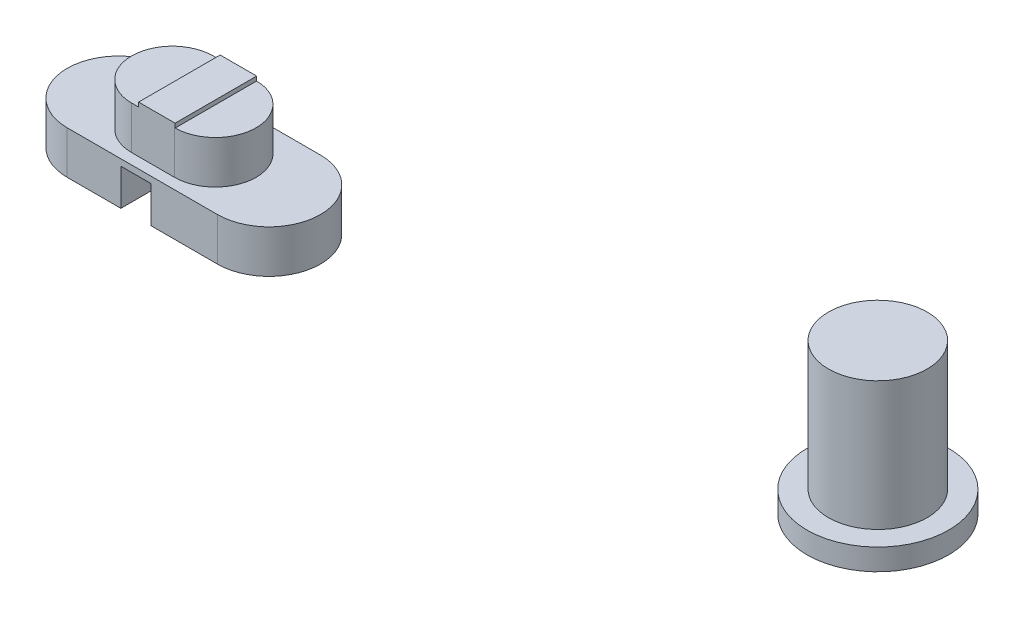
from build123d import *

# Parameters (mm, degrees)
SKETCH_1_R          = 3.3
EXTRUDE_1_DEPTH     = 1
SKETCH_1_3_R        = 2.3
EXTRUDE_2_DEPTH     = 6
EXTRUDE_3_DEPTH     = 2
EXTRUDE_4_DEPTH     = 2
SKETCH_2_W          = 1.4
SKETCH_2_H          = 1.7
CUT_EXTRUDE_1_DEPTH = 37.678033239
SKETCH_3_W          = 1.700465275
SKETCH_3_H          = 3.8
EXTRUDE_5_DEPTH     = 0.2


with BuildPart() as part:
    # 草图1 → 凸台-拉伸1 (new body)
    with BuildSketch(Plane(origin=(0, 0, 0), x_dir=(1, 0, 0), z_dir=(0, 1, 0))):
        Circle(SKETCH_1_R)
    extrude(amount=-EXTRUDE_1_DEPTH)

    # 草图1<3> → 凸台-拉伸2 (add)
    with BuildSketch(Plane(origin=(0, 0, 0), x_dir=(1, 0, 0), z_dir=(0, 1, 0))):
        Circle(SKETCH_1_3_R)
    extrude(amount=EXTRUDE_2_DEPTH)


with BuildPart() as body_2:
    # 草图1<5> → 凸台-拉伸3 (new body)
    with BuildSketch(Plane(origin=(0, 0, 0), x_dir=(1, 0, 0), z_dir=(0, 1, 0))):
        with BuildLine():
            Line((-26.464162089, 0.5), (-33.464162089, 0.5))
            ThreePointArc((-33.464162089, 0.5), (-35.864162089, -1.9), (-33.464162089, -4.3))
            Line((-33.464162089, -4.3), (-26.464162089, -4.3))
            ThreePointArc((-26.464162089, -4.3), (-24.064162089, -1.9), (-26.464162089, 0.5))
        make_face()
    extrude(amount=-EXTRUDE_3_DEPTH)

    # 草图1<6> → 凸台-拉伸4 (add)
    with BuildSketch(Plane(origin=(0, 0, 0), x_dir=(1, 0, 0), z_dir=(0, 1, 0))):
        with BuildLine():
            Line((-28.964162089, 0), (-30.964162089, 0))
            ThreePointArc((-30.964162089, 0), (-32.864162089, -1.9), (-30.964162089, -3.8))
            Line((-30.964162089, -3.8), (-28.964162089, -3.8))
            ThreePointArc((-28.964162089, -3.8), (-27.064162089, -1.9), (-28.964162089, 0))
        make_face()
    extrude(amount=EXTRUDE_4_DEPTH)

    # 草图2 → 切除-拉伸1 (cut, through all)
    with BuildSketch(Plane(origin=(0, 0, -0.5), x_dir=(-1, 0, 0), z_dir=(0, 0, -1))):
        with Locations((30.264162089, -1.15)):
            Rectangle(SKETCH_2_W, SKETCH_2_H)
    extrude(amount=-CUT_EXTRUDE_1_DEPTH, mode=Mode.SUBTRACT)

    # 草图3 → 凸台-拉伸5 (add)
    with BuildSketch(Plane(origin=(0, 2, 0), x_dir=(1, 0, 0), z_dir=(0, 1, 0))):
        with Locations((-29.788449326, -1.9)):
            Rectangle(SKETCH_3_W, SKETCH_3_H)
    extrude(amount=EXTRUDE_5_DEPTH)


solid = Compound([part.part, body_2.part])
